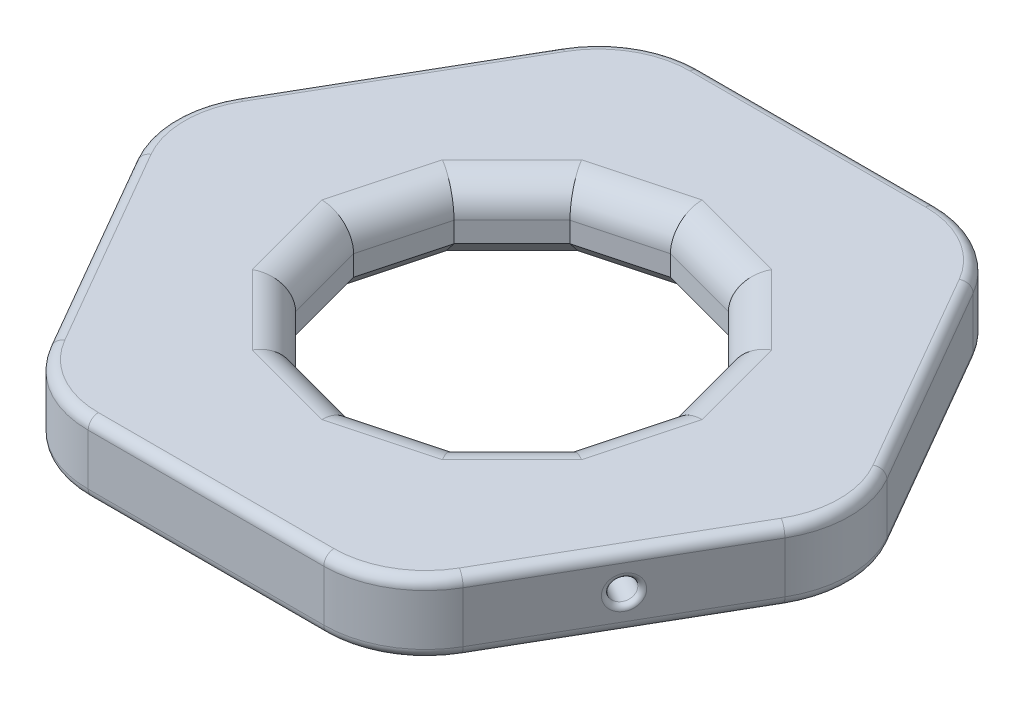
from build123d import *

# Parameters (mm, degrees)
SALIENTE_EXTRUIR1_DEPTH = 7
CROQUIS2_R              = 1.125
CORTAR_EXTRUIR1_DEPTH   = 10
CROQUIS4_R              = 1.125
CORTAR_EXTRUIR2_DEPTH   = 10
CROQUIS5_R              = 1.125
CORTAR_EXTRUIR3_DEPTH   = 10
REDONDEO1_R             = 10
REDONDEO2_R             = 0.5
REDONDEO3_R             = 1
CORTAR_EXTRUIR4_DEPTH   = 10
REDONDEO4_R             = 3
REDONDEO5_R             = 1
CHAFL_N1_SIZE           = 2


with BuildPart() as part:
    # Croquis1 → Saliente-Extruir1 (new body)
    with BuildSketch(Plane(origin=(0, 0, 0), x_dir=(1, 0, 0), z_dir=(0, 1, 0))):
        Polygon((34.641016151, 0), (17.320508076, 30), (-17.320508076, 30), (-34.641016151, 0), (-17.320508076, -30), (17.320508076, -30), align=None)
    extrude(amount=SALIENTE_EXTRUIR1_DEPTH)

    # Croquis2 → Cortar-Extruir1 (cut)
    with BuildSketch(Plane(origin=(25.980762114, 0, 15), x_dir=(0.5, 0, -0.866025404), z_dir=(0.866025404, 0, 0.5))):
        with Locations((0, 3.5)):
            Circle(CROQUIS2_R)
    extrude(amount=-CORTAR_EXTRUIR1_DEPTH, mode=Mode.SUBTRACT)

    # Croquis4 → Cortar-Extruir2 (cut)
    with BuildSketch(Plane(origin=(-25.980762114, 0, 15), x_dir=(0.5, 0, 0.866025404), z_dir=(-0.866025404, 0, 0.5))):
        with Locations((0, 3.5)):
            Circle(CROQUIS4_R)
    extrude(amount=-CORTAR_EXTRUIR2_DEPTH, mode=Mode.SUBTRACT)

    # Croquis5 → Cortar-Extruir3 (cut)
    with BuildSketch(Plane(origin=(0, 0, -30), x_dir=(-1, 0, 0), z_dir=(0, 0, -1))):
        with Locations((0, 3.5)):
            Circle(CROQUIS5_R)
    extrude(amount=-CORTAR_EXTRUIR3_DEPTH, mode=Mode.SUBTRACT)

    # Redondeo1
    redondeo1_edges = [part.edges().sort_by_distance(p)[0] for p in [
        (17.320508076, 3.5, 30),
        (-17.320508076, 3.5, 30),
        (-34.641016151, 3.5, 0),
        (-17.320508076, 3.5, -30),
        (17.320508076, 3.5, -30),
        (34.641016151, 3.5, 0),
    ]]
    fillet(redondeo1_edges, radius=REDONDEO1_R)

    # Redondeo2
    redondeo2_edges = [part.edges().sort_by_distance(p)[0] for p in [
        (25.418262114, 3.5, 15.974278579),
        (-26.543262114, 3.5, 14.025721421),
        (1.125, 3.5, -30),
    ]]
    fillet(redondeo2_edges, radius=REDONDEO2_R)

    # Redondeo3
    redondeo3_edges = [part.edges().sort_by_distance(p)[0] for p in [
        (25.980762114, 7, 15),
        (0, 7, 30),
        (25.980762114, 7, -15),
        (0, 7, -30),
        (-25.980762114, 7, -15),
        (-25.980762114, 7, 15),
        (-16.547005384, 7, -28.660254038),
        (-33.094010768, 7, 0),
        (-16.547005384, 7, 28.660254038),
        (16.547005384, 7, -28.660254038),
        (33.094010768, 7, 0),
        (16.547005384, 7, 28.660254038),
    ]]
    fillet(redondeo3_edges, radius=REDONDEO3_R)

    # Croquis6 → Cortar-Extruir4 (cut)
    with BuildSketch(Plane(origin=(0, 7, 0), x_dir=(1, 0, 0), z_dir=(0, 1, 0))):
        Polygon((-15.529142706, 0), (-13.448632083, -7.764571353), (-7.764571353, -13.448632083), (0, -15.529142706), (7.764571353, -13.448632083), (13.448632083, -7.764571353), (15.529142706, 0), (13.448632083, 7.764571353), (7.764571353, 13.448632083), (0, 15.529142706), (-7.764571353, 13.448632083), (-13.448632083, 7.764571353), align=None)
    extrude(amount=-CORTAR_EXTRUIR4_DEPTH, mode=Mode.SUBTRACT)

    # Redondeo4
    redondeo4_edges = [part.edges().sort_by_distance(p)[0] for p in [
        (-14.488887394, 7, -3.882285677),
        (-14.488887394, 7, 3.882285677),
        (-10.606601718, 7, 10.606601718),
        (-3.882285677, 7, 14.488887394),
        (3.882285677, 7, 14.488887394),
        (10.606601718, 7, 10.606601718),
        (14.488887394, 7, 3.882285677),
        (14.488887394, 7, -3.882285677),
        (10.606601718, 7, -10.606601718),
        (3.882285677, 7, -14.488887394),
        (-3.882285677, 7, -14.488887394),
        (-10.606601718, 7, -10.606601718),
    ]]
    fillet(redondeo4_edges, radius=REDONDEO4_R)

    # Redondeo5
    redondeo5_edges = [part.edges().sort_by_distance(p)[0] for p in [
        (25.980762114, 0, 15),
        (0, 0, 30),
        (-25.980762114, 0, 15),
        (-25.980762114, 0, -15),
        (0, 0, -30),
        (25.980762114, 0, -15),
        (-16.547005384, 0, -28.660254038),
        (-33.094010768, 0, 0),
        (-16.547005384, 0, 28.660254038),
        (16.547005384, 0, -28.660254038),
        (33.094010768, 0, 0),
        (16.547005384, 0, 28.660254038),
    ]]
    fillet(redondeo5_edges, radius=REDONDEO5_R)

    # Chaflán1
    chafl_n1_edges = [part.edges().sort_by_distance(p)[0] for p in [
        (-14.488887394, 0, 3.882285677),
        (-10.606601718, 0, 10.606601718),
        (-3.882285677, 0, 14.488887394),
        (3.882285677, 0, 14.488887394),
        (10.606601718, 0, 10.606601718),
        (14.488887394, 0, 3.882285677),
        (14.488887394, 0, -3.882285677),
        (10.606601718, 0, -10.606601718),
        (3.882285677, 0, -14.488887394),
        (-3.882285677, 0, -14.488887394),
        (-10.606601718, 0, -10.606601718),
        (-14.488887394, 0, -3.882285677),
    ]]
    chamfer(chafl_n1_edges, length=CHAFL_N1_SIZE)


solid = part.part
